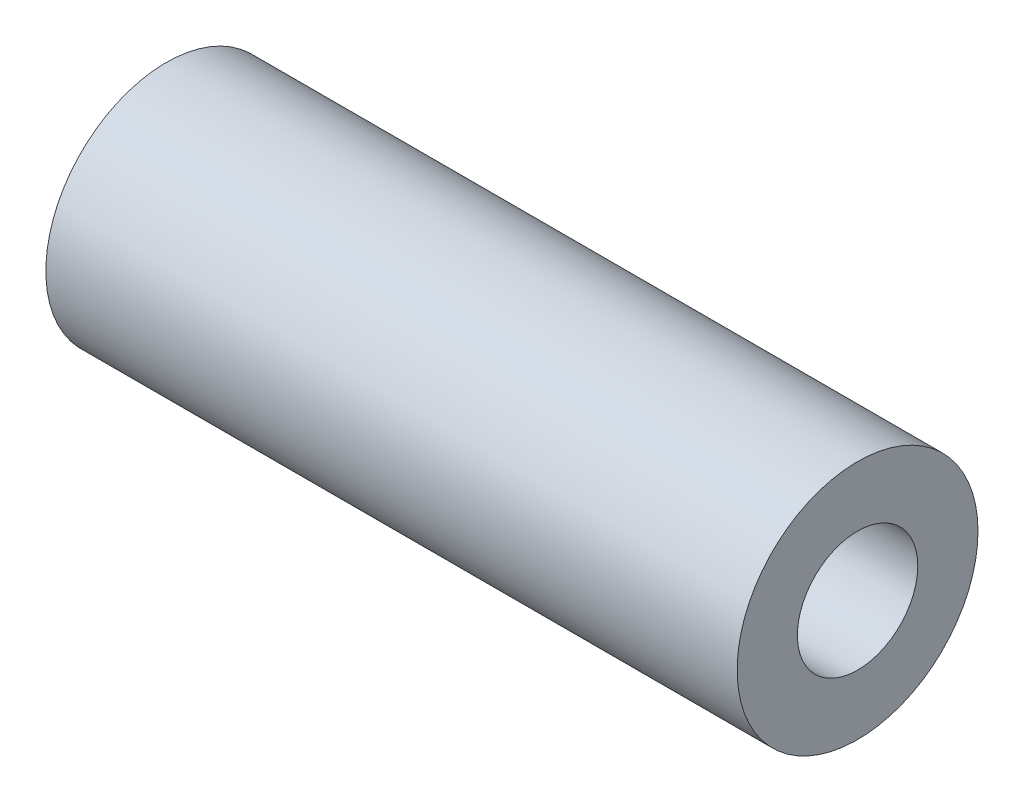
from build123d import *

# Parameters (mm, degrees)
SKETCH1_R           = 6.35
SKETCH1_R_2         = 3.175
BOSS_EXTRUDE1_DEPTH = 36.449


with BuildPart() as part:
    # Sketch1 → Boss-Extrude1 (new body)
    with BuildSketch(Plane(origin=(0, 0, 0), x_dir=(0, 0, -1), z_dir=(1, 0, 0))):
        Circle(SKETCH1_R)
        Circle(SKETCH1_R_2, mode=Mode.SUBTRACT)
    extrude(amount=BOSS_EXTRUDE1_DEPTH)


solid = part.part
